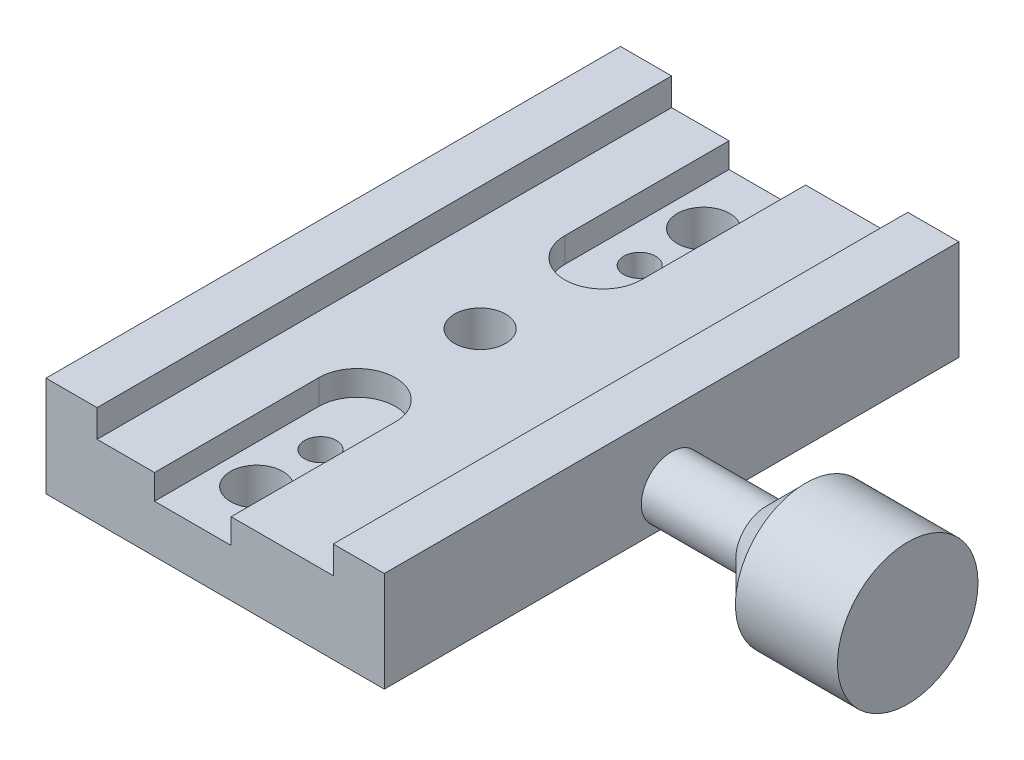
from build123d import *

# Parameters (mm, degrees)
BOSS_EXTRUDE1_DEPTH = 90
SKETCH2_R           = 4.75
BOSS_EXTRUDE2_DEPTH = 37
SKETCH3_R           = 11
BOSS_EXTRUDE3_DEPTH = 16
CHAMFER1_SIZE       = 6.2
SKETCH4_R           = 4
SKETCH4_R_2         = 2.5
SKETCH4_R_3         = 4.1
CUT_EXTRUDE1_DEPTH  = 16.97152885
CUT_EXTRUDE2_DEPTH  = 3.9


with BuildPart() as part:
    # Sketch1 → Boss-Extrude1 (new body)
    with BuildSketch(Plane.XY):
        Polygon((0, 0), (30, 0), (30, 15.7), (22, 15.7), (22, 11.4), (0, 11.4), (-15, 11.4), (-15, 15.7), (-23, 15.7), (-23, 0), align=None)
    extrude(amount=BOSS_EXTRUDE1_DEPTH)

    # Sketch2 → Boss-Extrude2 (add)
    with BuildSketch(Plane(origin=(30, 0, 0), x_dir=(0, 0, -1), z_dir=(1, 0, 0))):
        with Locations((-45, 4.97152885)):
            Circle(SKETCH2_R)
    extrude(amount=BOSS_EXTRUDE2_DEPTH)

    # Sketch3 → Boss-Extrude3 (add)
    with BuildSketch(Plane(origin=(67, 0, 0), x_dir=(0, 0, -1), z_dir=(1, 0, 0))):
        with Locations((-45, 4.97152885)):
            Circle(SKETCH3_R)
    extrude(amount=-BOSS_EXTRUDE3_DEPTH)

    # Chamfer1
    chamfer1_edges = [part.edges().sort_by_distance(p)[0] for p in [
        (51, 4.97152885, 49.75),
    ]]
    chamfer(chamfer1_edges, length=CHAMFER1_SIZE)

    # Sketch4 → Cut-Extrude1 (cut, through all)
    with BuildSketch(Plane(origin=(0, 0, 0), x_dir=(1, 0, 0), z_dir=(0, 1, 0))):
        with Locations((0, -45)):
            Circle(SKETCH4_R)
        with Locations((0, -20)):
            Circle(SKETCH4_R_2)
        with Locations((0, -70)):
            Circle(SKETCH4_R_2)
        with Locations((0, -10)):
            Circle(SKETCH4_R_3)
        with Locations((0, -80)):
            Circle(SKETCH4_R_3)
    extrude(amount=CUT_EXTRUDE1_DEPTH, mode=Mode.SUBTRACT)

    # Sketch5 → Cut-Extrude2 (cut)
    with BuildSketch(Plane(origin=(0, 11.4, 0), x_dir=(1, 0, 0), z_dir=(0, 1, 0))):
        with BuildLine():
            Line((-6, -25.72942469), (-6, 7.985784124))
            ThreePointArc((-6, 7.985784124), (0, 13.985784124), (6, 7.985784124))
            Line((6, 7.985784124), (6, -25.72942469))
            ThreePointArc((6, -25.72942469), (0, -31.72942469), (-6, -25.72942469))
        make_face()
        with BuildLine():
            Line((-6, -64.27057531), (-6, -97.985784124))
            ThreePointArc((-6, -97.985784124), (0, -103.985784124), (6, -97.985784124))
            Line((6, -97.985784124), (6, -64.27057531))
            ThreePointArc((6, -64.27057531), (0, -58.27057531), (-6, -64.27057531))
        make_face()
    extrude(amount=-CUT_EXTRUDE2_DEPTH, mode=Mode.SUBTRACT)


solid = part.part
